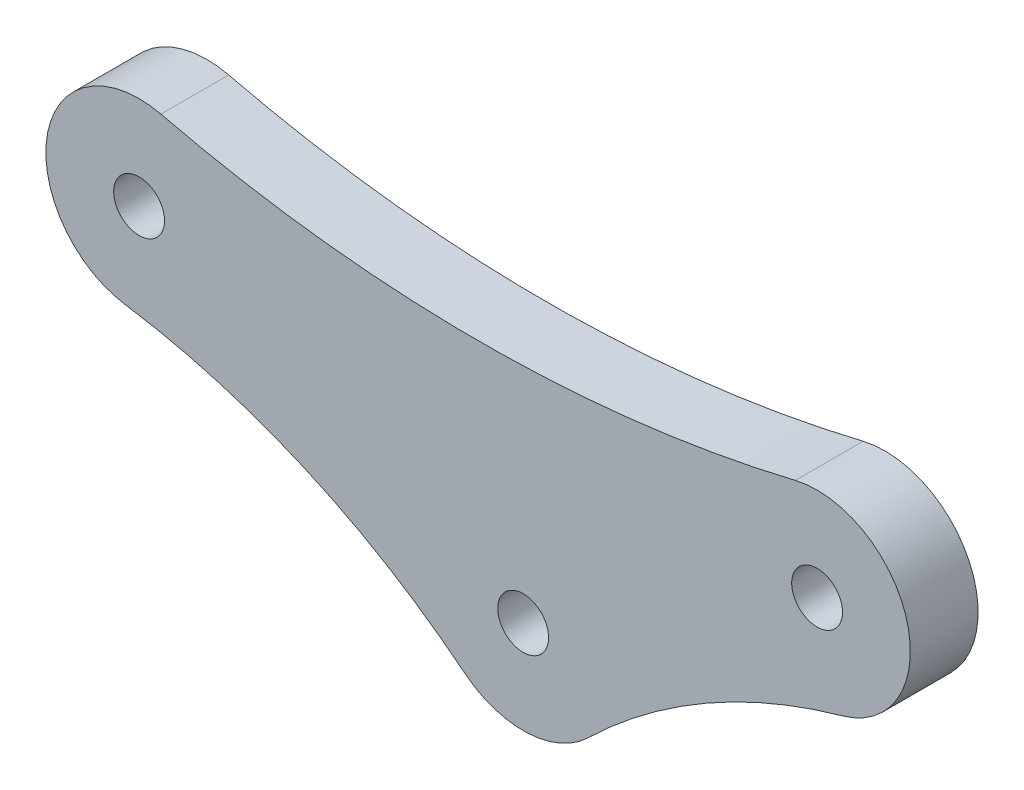
from build123d import *

# Parameters (mm, degrees)
SKETCH1_R           = 1.5
BOSS_EXTRUDE1_DEPTH = 4


with BuildPart() as part:
    # Sketch1 → Boss-Extrude1 (new body)
    with BuildSketch(Plane.XY):
        with BuildLine():
            ThreePointArc((-38.713450292, 5.347409639), (-45.397441252, 1.057179235), (-40.825882635, -5.437638998))
            ThreePointArc((-40.825882635, -5.437638998), (-30.223624193, -8.515546688), (-20.789672108, -14.24982501))
            ThreePointArc((-20.789672108, -14.24982501), (-17.086113442, -15.460299774), (-13.509973062, -13.913426824))
            ThreePointArc((-13.509973062, -13.913426824), (-6.552111329, -8.667968977), (1.482746603, -5.29636314))
            ThreePointArc((1.482746603, -5.29636314), (5.322790438, 1.384883371), (-1.286549708, 5.347409639))
            ThreePointArc((-1.286549708, 5.347409639), (-20, 3.127913483), (-38.713450292, 5.347409639))
        make_face()
        with Locations((-40, 0)):
            Circle(SKETCH1_R, mode=Mode.SUBTRACT)
        Circle(SKETCH1_R, mode=Mode.SUBTRACT)
        with Locations((-17.34, -9.966162752)):
            Circle(SKETCH1_R, mode=Mode.SUBTRACT)
    extrude(amount=BOSS_EXTRUDE1_DEPTH)


solid = part.part
